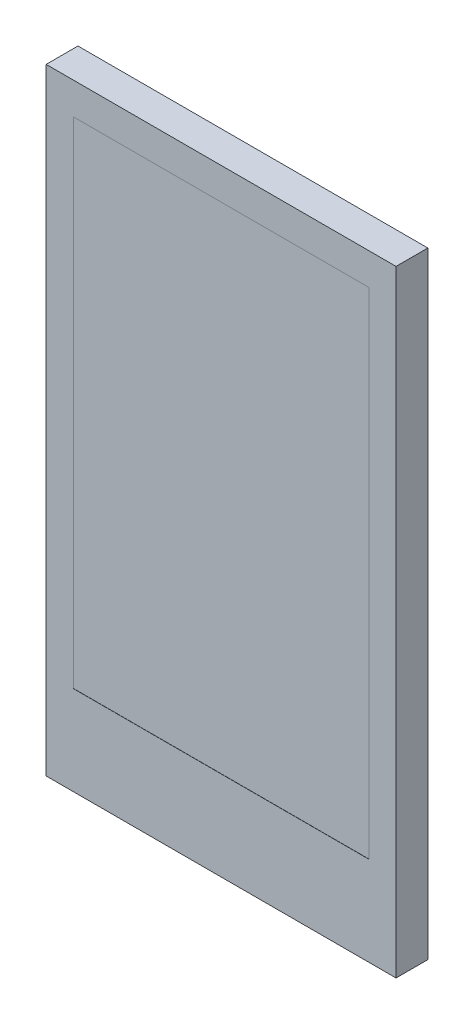
from build123d import *

# Parameters (mm, degrees)
SKETCH_1_W          = 17.6
SKETCH_1_H          = 31
EXTRUDE_1_DEPTH     = 1.6
SKETCH_2_W          = 14.86
SKETCH_2_H          = 24.91
CUT_EXTRUDE_1_DEPTH = 0.01


with BuildPart() as part:
    # 草图1 → 凸台-拉伸1 (new body)
    with BuildSketch(Plane.XY):
        Rectangle(SKETCH_1_W, SKETCH_1_H)
    extrude(amount=EXTRUDE_1_DEPTH)

    # 草图2 → 切除-拉伸1 (cut)
    with BuildSketch(Plane.XY.offset(1.6)):
        with Locations((0, 1.445)):
            Rectangle(SKETCH_2_W, SKETCH_2_H)
    extrude(amount=-CUT_EXTRUDE_1_DEPTH, mode=Mode.SUBTRACT)


solid = part.part
